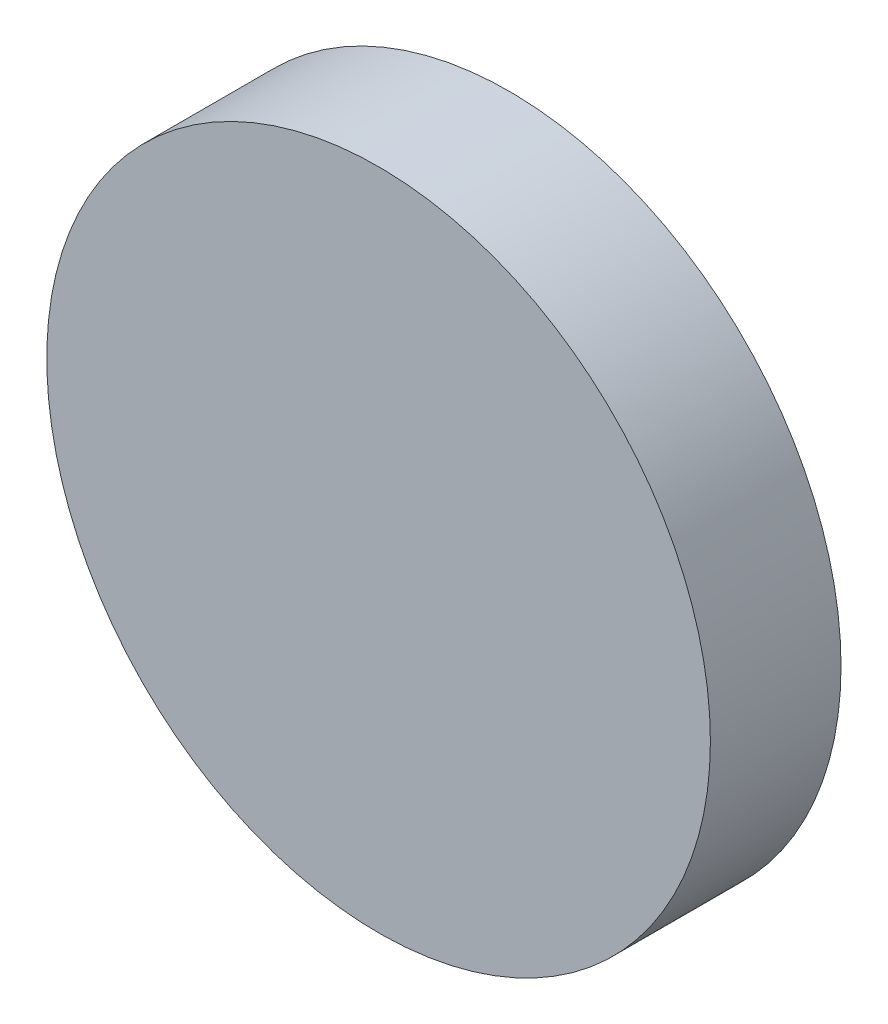
from build123d import *

# Parameters (mm, degrees)
SKETCH_1_R      = 25.4
EXTRUDE_1_DEPTH = 10


with BuildPart() as part:
    # 草图1 → 凸台-拉伸1 (new body)
    with BuildSketch(Plane.XY):
        Circle(SKETCH_1_R)
    extrude(amount=EXTRUDE_1_DEPTH)


solid = part.part
